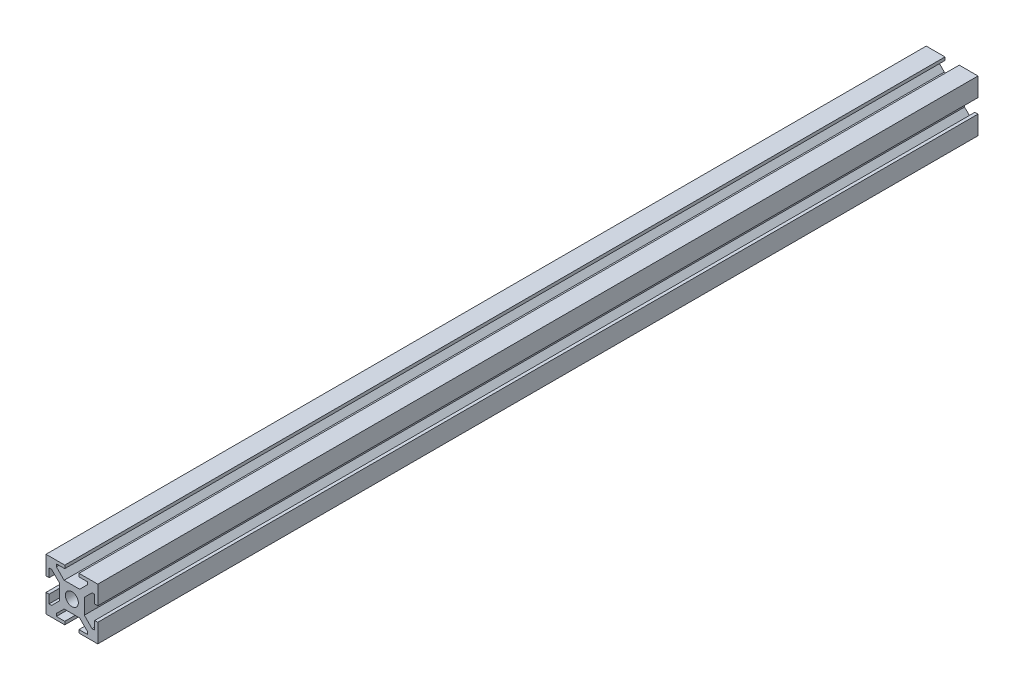
from build123d import *

# Parameters (mm, degrees)
ESQUISSE1_W             = 20
ESQUISSE1_H             = 20
BOSS_EXTRU_1_DEPTH      = 340
ESQUISSE2_W             = 1.2
ESQUISSE2_H             = 5.5
ESQUISSE2_W_2           = 5.5
ESQUISSE2_H_2           = 1.2
ENL_V_MAT_EXTRU_1_DEPTH = 341
ENL_V_MAT_EXTRU_2_DEPTH = 341
ESQUISSE4_R             = 2.5
ENL_V_MAT_EXTRU_3_DEPTH = 341


with BuildPart() as part:
    # Esquisse1 → Boss.-Extru.1 (new body)
    with BuildSketch(Plane.XY):
        with Locations((-12.505109137, -9.909560068)):
            Rectangle(ESQUISSE1_W, ESQUISSE1_H)
    extrude(amount=BOSS_EXTRU_1_DEPTH)

    # Esquisse2 → Enlèv. mat.-Extru.1 (cut, through all)
    with BuildSketch(Plane.XY.offset(340)):
        with Locations((-21.905109137, -9.909560068)):
            Rectangle(ESQUISSE2_W, ESQUISSE2_H)
        with Locations((-12.505109137, -0.509560068)):
            Rectangle(ESQUISSE2_W_2, ESQUISSE2_H_2)
        with Locations((-3.105109137, -9.909560068)):
            Rectangle(ESQUISSE2_W, ESQUISSE2_H)
        with Locations((-12.505109137, -19.309560068)):
            Rectangle(ESQUISSE2_W_2, ESQUISSE2_H_2)
    extrude(amount=-ENL_V_MAT_EXTRU_1_DEPTH, mode=Mode.SUBTRACT)

    # Esquisse3 → Enlèv. mat.-Extru.2 (cut, through all)
    with BuildSketch(Plane.XY.offset(340)):
        Polygon((-21.305109137, -15.909560068), (-20.305109137, -15.909560068), (-17.305109137, -12.909560068), (-17.305109137, -6.909560068), (-20.305109137, -3.909560068), (-21.305109137, -3.909560068), align=None)
        Polygon((-18.505109137, -1.109560068), (-6.505109137, -1.109560068), (-6.505109137, -2.109560068), (-9.505109137, -5.109560068), (-15.505109137, -5.109560068), (-18.505109137, -2.109560068), align=None)
        Polygon((-3.705109137, -3.909560068), (-4.705109137, -3.909560068), (-7.705109137, -6.909560068), (-7.705109137, -12.909560068), (-4.705109137, -15.909560068), (-3.705109137, -15.909560068), align=None)
        Polygon((-6.505109137, -18.709560068), (-18.505109137, -18.709560068), (-18.505109137, -17.709560068), (-15.505109137, -14.709560068), (-9.505109137, -14.709560068), (-6.505109137, -17.709560068), align=None)
    extrude(amount=-ENL_V_MAT_EXTRU_2_DEPTH, mode=Mode.SUBTRACT)

    # Esquisse4 → Enlèv. mat.-Extru.3 (cut, through all)
    with BuildSketch(Plane.XY.offset(340)):
        with Locations((-12.505109137, -9.909560068)):
            Circle(ESQUISSE4_R)
    extrude(amount=-ENL_V_MAT_EXTRU_3_DEPTH, mode=Mode.SUBTRACT)


solid = part.part
